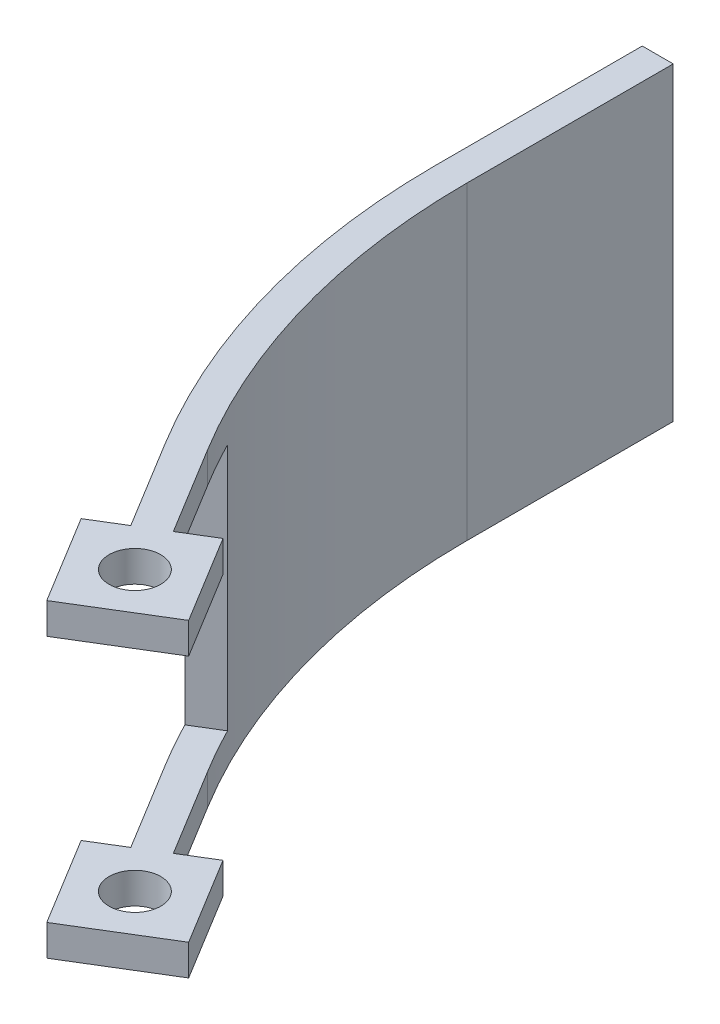
from build123d import *

# Parameters (mm, degrees)
ESQUISSE1_R      = 2.5
EXTRUSION1_DEPTH = 30
ESQUISSE3_W      = 25
ESQUISSE3_H      = 24
EXTRUSION2_DEPTH = 47.542124281


with BuildPart() as part:
    # Esquisse1 → Extrusion1 (new body)
    with BuildSketch(Plane(origin=(0, 0, 0), x_dir=(1, 0, 0), z_dir=(0, 1, 0))):
        with BuildLine():
            Line((0, 0), (0, 20))
            Line((0, 20), (3, 20))
            Line((3, 20), (3, 0))
            ThreePointArc((3, 0), (5.498625566, -18.126574307), (12.808140182, -34.901162883))
            Line((12.808140182, -34.901162883), (18.017268971, -43.437261363))
            Line((18.017268971, -43.437261363), (21.004903439, -41.614066287))
            Line((21.004903439, -41.614066287), (26.214032228, -50.150164768))
            Line((26.214032228, -50.150164768), (17.677933747, -55.359293556))
            Line((17.677933747, -55.359293556), (12.468804959, -46.823195076))
            Line((12.468804959, -46.823195076), (15.456439427, -45))
            Line((15.456439427, -45), (10.247310638, -36.46390152))
            ThreePointArc((10.247310638, -36.46390152), (2.610504323, -18.938211963), (0, 0))
        make_face()
        with Locations((19.341418593, -48.486679922)):
            Circle(ESQUISSE1_R, mode=Mode.SUBTRACT)
    extrude(amount=EXTRUSION1_DEPTH)

    # Esquisse3 → Extrusion2 (cut, through all)
    with BuildSketch(Plane(origin=(-11.734839745, 0, 7.161151161), x_dir=(0.520912879, 0, 0.853609848), z_dir=(-0.853609848, 0, 0.520912879))):
        with Locations((43.96390152, 15)):
            Rectangle(ESQUISSE3_W, ESQUISSE3_H)
    extrude(amount=-EXTRUSION2_DEPTH, mode=Mode.SUBTRACT)


solid = part.part
